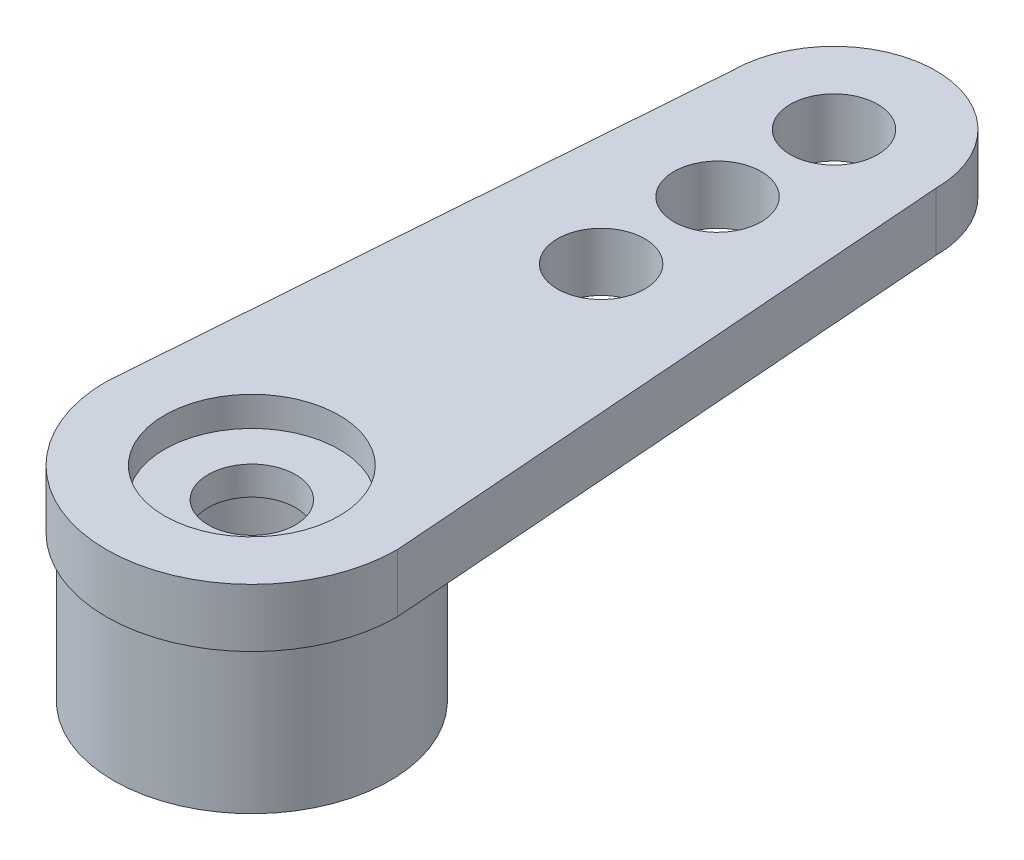
from build123d import *

# Parameters (mm, degrees)
BOSS_EXTRUDE1_DEPTH = 2
SKETCH2_R           = 1.5
CUT_EXTRUDE1_DEPTH  = 3
SKETCH7_R           = 4.75
BOSS_EXTRUDE2_DEPTH = 5
SKETCH3_R           = 1.5
CUT_EXTRUDE2_DEPTH  = 8
SKETCH4_R           = 3
CUT_EXTRUDE3_DEPTH  = 1.016
SKETCH6_R           = 1.5
CUT_EXTRUDE4_DEPTH  = 8
SKETCH5_R           = 1.5
CUT_EXTRUDE5_DEPTH  = 8
SKETCH8_R           = 3
CUT_EXTRUDE6_DEPTH  = 5


with BuildPart() as part:
    # Sketch1 → Boss-Extrude1 (new body)
    with BuildSketch(Plane(origin=(0, 0, 0), x_dir=(1, 0, 0), z_dir=(0, 1, 0))):
        with BuildLine():
            Line((3.5, 20), (5, 0))
            ThreePointArc((5, 0), (0, -5), (-5, 0))
            Line((-5, 0), (-3.5, 20))
            ThreePointArc((-3.5, 20), (0, 23.5), (3.5, 20))
        make_face()
    extrude(amount=BOSS_EXTRUDE1_DEPTH)

    # Sketch2 → Cut-Extrude1 (cut, through all)
    with BuildSketch(Plane(origin=(0, 2, 0), x_dir=(1, 0, 0), z_dir=(0, 1, 0))):
        with Locations((0, 20)):
            Circle(SKETCH2_R)
    extrude(amount=-CUT_EXTRUDE1_DEPTH, mode=Mode.SUBTRACT)

    # Sketch7 → Boss-Extrude2 (add)
    with BuildSketch(Plane(origin=(0, 0, 0), x_dir=(-1, 0, 0), z_dir=(0, -1, 0))):
        Circle(SKETCH7_R)
    extrude(amount=BOSS_EXTRUDE2_DEPTH)

    # Sketch3 → Cut-Extrude2 (cut, through all)
    with BuildSketch(Plane(origin=(0, 2, 0), x_dir=(1, 0, 0), z_dir=(0, 1, 0))):
        Circle(SKETCH3_R)
    extrude(amount=-CUT_EXTRUDE2_DEPTH, mode=Mode.SUBTRACT)

    # Sketch4 → Cut-Extrude3 (cut)
    with BuildSketch(Plane(origin=(0, 2, 0), x_dir=(1, 0, 0), z_dir=(0, 1, 0))):
        Circle(SKETCH4_R)
    extrude(amount=-CUT_EXTRUDE3_DEPTH, mode=Mode.SUBTRACT)

    # Sketch6 → Cut-Extrude4 (cut, through all)
    with BuildSketch(Plane(origin=(0, 2, 0), x_dir=(1, 0, 0), z_dir=(0, 1, 0))):
        with Locations((0, 16)):
            Circle(SKETCH6_R)
    extrude(amount=-CUT_EXTRUDE4_DEPTH, mode=Mode.SUBTRACT)

    # Sketch5 → Cut-Extrude5 (cut, through all)
    with BuildSketch(Plane(origin=(0, 2, 0), x_dir=(1, 0, 0), z_dir=(0, 1, 0))):
        with Locations((0, 12)):
            Circle(SKETCH5_R)
    extrude(amount=-CUT_EXTRUDE5_DEPTH, mode=Mode.SUBTRACT)

    # Sketch8 → Cut-Extrude6 (cut)
    with BuildSketch(Plane(origin=(0, -5, 0), x_dir=(-1, 0, 0), z_dir=(0, -1, 0))):
        Circle(SKETCH8_R)
    extrude(amount=-CUT_EXTRUDE6_DEPTH, mode=Mode.SUBTRACT)


solid = part.part
